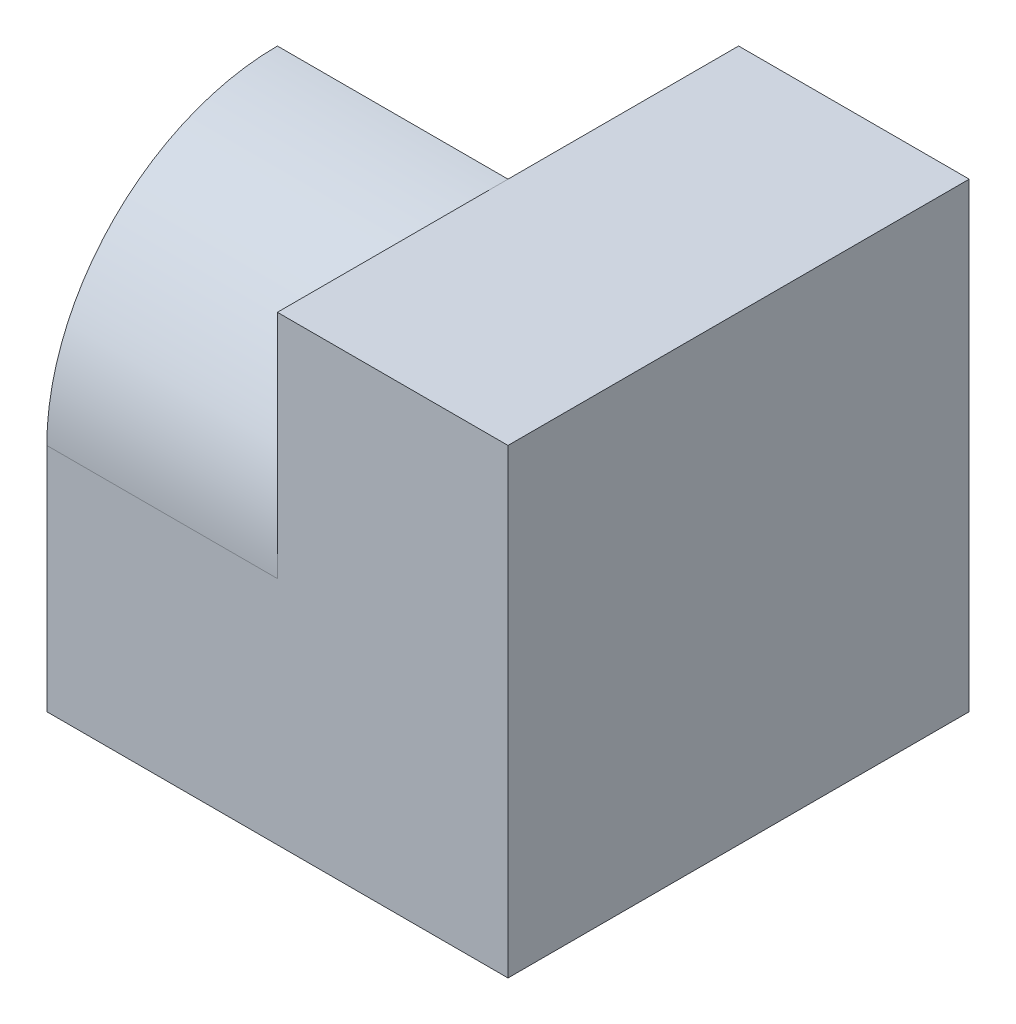
from build123d import *

# Parameters (mm, degrees)
SKETCH1_W           = 4
SKETCH1_H           = 4
BOSS_EXTRUDE1_DEPTH = 4
CUT_EXTRUDE1_DEPTH  = 2


with BuildPart() as part:
    # Sketch1 → Boss-Extrude1 (new body)
    with BuildSketch(Plane(origin=(0, 0, 0), x_dir=(1, 0, 0), z_dir=(0, 1, 0))):
        Rectangle(SKETCH1_W, SKETCH1_H)
    extrude(amount=BOSS_EXTRUDE1_DEPTH)

    # Sketch2 → Cut-Extrude1 (cut)
    with BuildSketch(Plane.ZY.offset(2)):
        Polygon((-2, 2), (0, 4), (-2, 4), align=None)
        with BuildLine():
            Line((2, 4), (0, 4))
            ThreePointArc((0, 4), (1.414213562, 3.414213562), (2, 2))
            Line((2, 2), (2, 4))
        make_face()
    extrude(amount=-CUT_EXTRUDE1_DEPTH, mode=Mode.SUBTRACT)


solid = part.part
